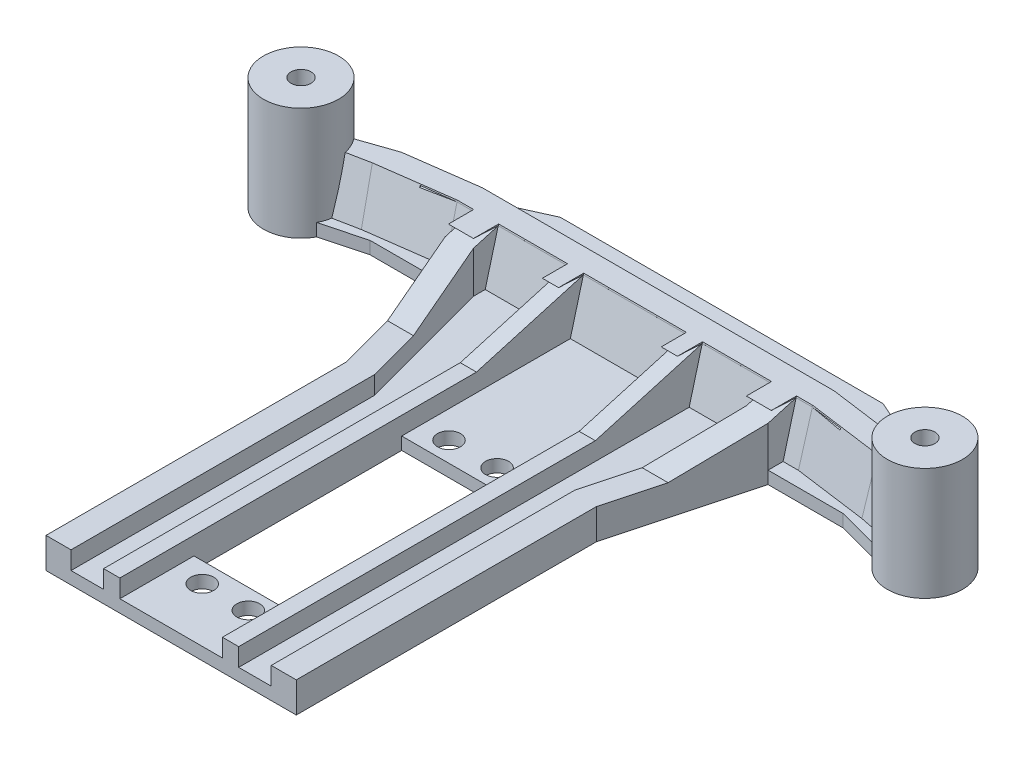
from build123d import *

# Parameters (mm, degrees)
BOSS_EXTRUDE1_DEPTH      = 2.5
SKETCH2_W                = 20.5
SKETCH2_H                = 41.5
CUT_EXTRUDE1_DEPTH       = 3.5
SKETCH8_R                = 2.3
CUT_EXTRUDE2_DEPTH       = 3.5
BOSS_EXTRUDE2_DEPTH      = 10
BOSS_EXTRUDE2_TAPER      = 15
SKETCH10_R               = 7.5
BOSS_EXTRUDE3_DEPTH      = 20
BOSS_EXTRUDE3_DEPTH_BACK = 2.5
SKETCH11_R               = 2
CUT_EXTRUDE3_DEPTH       = 23.5
BOSS_EXTRUDE7_DEPTH      = 10
CUT_EXTRUDE4_DEPTH       = 42
CUT_EXTRUDE4_DEPTH_BACK  = 42


with BuildPart() as part:
    # Sketch1 → Boss-Extrude1 (new body)
    with BuildSketch(Plane(origin=(0, 0, 0), x_dir=(1, 0, 0), z_dir=(0, 1, 0))):
        Polygon((-25, 30), (-32.256053395, 57), (-47.256053395, 57), (-66, 52), (-66, 62), (-50, 72), (-32.256053395, 80), (32.256053395, 80), (50, 72), (66, 62), (66, 52), (47.256053395, 57), (32.256053395, 57), (25, 30), (25, -30), (-25, -30), align=None)
    extrude(amount=BOSS_EXTRUDE1_DEPTH)

    # Sketch2 → Cut-Extrude1 (cut, through all)
    with BuildSketch(Plane(origin=(0, 2.5, 0), x_dir=(1, 0, 0), z_dir=(0, 1, 0))):
        with Locations((0, 5.559891181)):
            Rectangle(SKETCH2_W, SKETCH2_H)
    extrude(amount=-CUT_EXTRUDE1_DEPTH, mode=Mode.SUBTRACT)

    # Sketch8 → Cut-Extrude2 (cut, through all)
    with BuildSketch(Plane(origin=(0, 2.5, 0), x_dir=(1, 0, 0), z_dir=(0, 1, 0))):
        with Locations((-4.8, 30.309891181)):
            Circle(SKETCH8_R)
        with Locations((4.8, 30.309891181)):
            Circle(SKETCH8_R)
        with Locations((-4.6, -19.190108819)):
            Circle(SKETCH8_R)
        with Locations((4.6, -19.190108819)):
            Circle(SKETCH8_R)
    extrude(amount=-CUT_EXTRUDE2_DEPTH, mode=Mode.SUBTRACT)

    # Sketch9 → Boss-Extrude2 (add)
    with BuildSketch(Plane(origin=(0, 2.5, 0), x_dir=(1, 0, 0), z_dir=(0, 1, 0))):
        Polygon((-65, 62.845048963), (-65, 55), (-50, 58), (-35.31985343, 60), (35.31985343, 60), (50, 58), (65, 55), (65, 62.845048963), (50, 68), (35.31985343, 70), (-35.31985343, 70), (-50, 68), align=None)
    extrude(amount=BOSS_EXTRUDE2_DEPTH, taper=BOSS_EXTRUDE2_TAPER)

    # Sketch10 → Boss-Extrude3 (add, two sides)
    with BuildSketch(Plane(origin=(0, 2.5, 0), x_dir=(1, 0, 0), z_dir=(0, 1, 0))) as boss_extrude3_sk:
        with Locations((-62.320508076, 58.268454707)):
            Circle(SKETCH10_R)
        with Locations((62.320508076, 58.268454707)):
            Circle(SKETCH10_R)
    extrude(amount=BOSS_EXTRUDE3_DEPTH)
    extrude(boss_extrude3_sk.sketch, amount=-BOSS_EXTRUDE3_DEPTH_BACK)

    # Sketch11 → Cut-Extrude3 (cut, through all)
    with BuildSketch(Plane(origin=(0, 22.5, 0), x_dir=(1, 0, 0), z_dir=(0, 1, 0))):
        with Locations((-62.320508076, 58.268454707)):
            Circle(SKETCH11_R)
        with Locations((62.320508076, 58.268454707)):
            Circle(SKETCH11_R)
    extrude(amount=-CUT_EXTRUDE3_DEPTH, mode=Mode.SUBTRACT)

    # Sketch12 → Boss-Extrude7 (add)
    with BuildSketch(Plane(origin=(0, 2.5, 0), x_dir=(1, 0, 0), z_dir=(0, 1, 0))):
        Polygon((-25, -30), (-25, 30), (-32.256053395, 57), (-32.256053395, 65.259387318), (-27.256053395, 65.259387318), (-27.256053395, 57.660145211), (-20, 30.660145211), (-20, -30), align=None)
        Polygon((-10.25, -15.190108819), (-10.25, -30), (-13.493333109, -30), (-13.493333109, 64.72993517), (-10.25, 64.72993517), (-10.25, 26.309891181), align=None)
    boss_extrude7 = extrude(amount=BOSS_EXTRUDE7_DEPTH)

    # Mirror2: Boss-Extrude7 across plane
    add(boss_extrude7.mirror(Plane(origin=(0, 0, 0), x_dir=(0, 0, 1), z_dir=(1, 0, 0))))

    # Sketch13 → Cut-Extrude4 (cut, two sides)
    with BuildSketch(Plane(origin=(0, 0, 0), x_dir=(0, 0, -1), z_dir=(1, 0, 0))) as cut_extrude4_sk:
        Polygon((-30, 6.091325502), (41.254032245, 6.091325502), (62.608757253, 12.229145442), (-30, 17.289989114), align=None)
    extrude(amount=CUT_EXTRUDE4_DEPTH, mode=Mode.SUBTRACT)
    extrude(cut_extrude4_sk.sketch, amount=-CUT_EXTRUDE4_DEPTH_BACK, mode=Mode.SUBTRACT)


solid = part.part
